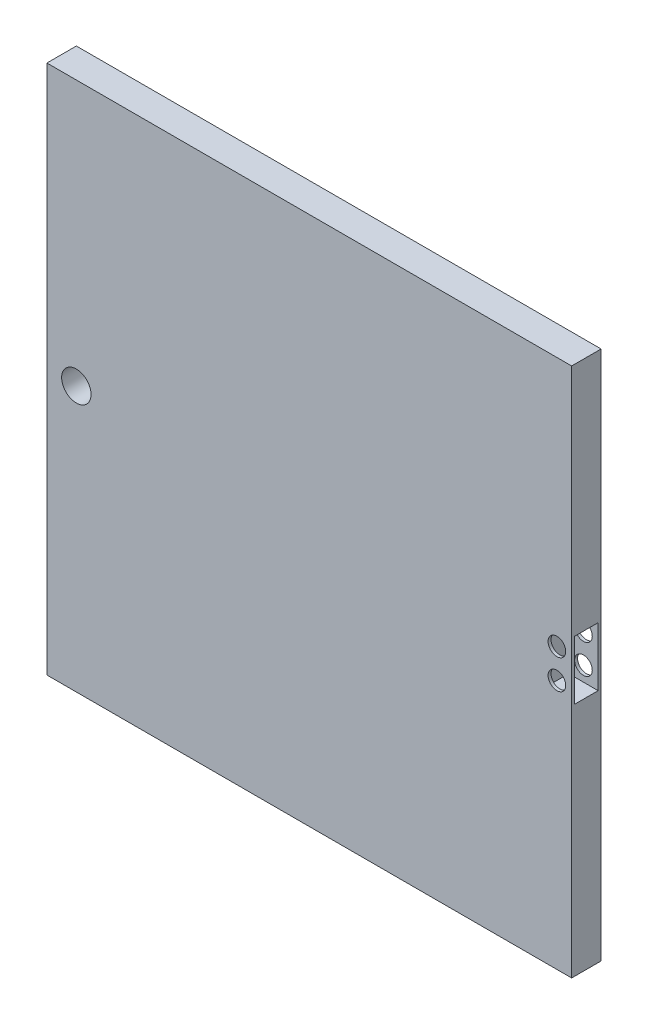
from build123d import *

# Parameters (mm, degrees)
SKETCH1_W           = 226.314
SKETCH1_H           = 215.9
BOSS_EXTRUDE1_DEPTH = 12.7
SKETCH2_W           = 10.16
SKETCH2_H           = 25.4
CUT_EXTRUDE1_DEPTH  = 12.7
SKETCH3_R           = 6.35
SKETCH3_R_2         = 3.81
CUT_EXTRUDE2_DEPTH  = 12.7
SKETCH4_W           = 226.314
SKETCH4_H           = 12.7
BOSS_EXTRUDE2_DEPTH = 12.7


with BuildPart() as part:
    # Sketch1 → Boss-Extrude1 (new body)
    with BuildSketch(Plane.XY):
        with Locations((34.929769953, -18.751877934)):
            Rectangle(SKETCH1_W, SKETCH1_H)
    extrude(amount=BOSS_EXTRUDE1_DEPTH)

    # Sketch2 → Cut-Extrude1 (cut)
    with BuildSketch(Plane(origin=(148.086769953, 0, 0), x_dir=(0, 0, -1), z_dir=(1, 0, 0))):
        with Locations((-6.35, -12.393940124)):
            Rectangle(SKETCH2_W, SKETCH2_H)
    extrude(amount=-CUT_EXTRUDE1_DEPTH, mode=Mode.SUBTRACT)

    # Sketch3 → Cut-Extrude2 (cut)
    with BuildSketch(Plane.XY.offset(12.7)):
        with Locations((-65.527230047, -12.401877934)):
            Circle(SKETCH3_R)
        with Locations((141.736769953, -6.043940124)):
            Circle(SKETCH3_R_2)
        with Locations((141.736769953, -18.743940124)):
            Circle(SKETCH3_R_2)
    extrude(amount=-CUT_EXTRUDE2_DEPTH, mode=Mode.SUBTRACT)

    # Sketch4 → Boss-Extrude2 (add)
    with BuildSketch(Plane(origin=(0, 89.198122066, 0), x_dir=(1, 0, 0), z_dir=(0, 1, 0))):
        with Locations((34.929769953, -6.35)):
            Rectangle(SKETCH4_W, SKETCH4_H)
    extrude(amount=BOSS_EXTRUDE2_DEPTH)


solid = part.part
